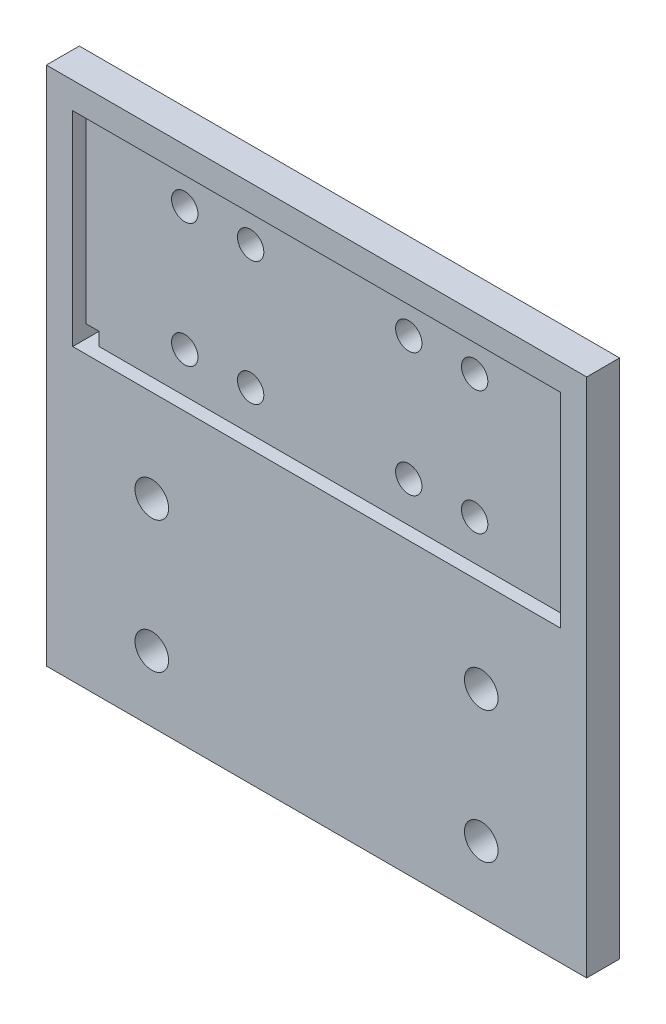
from build123d import *

# Parameters (mm, degrees)
SKETCH1_R           = 2.55
BOSS_EXTRUDE1_DEPTH = 5
SKETCH3_R           = 2.55
SKETCH3_W           = 74
SKETCH3_H           = 31
CUT_EXTRUDE1_DEPTH  = 2
SKETCH4_R           = 2
SKETCH4_W           = 2
SKETCH4_H           = 2
CUT_EXTRUDE2_DEPTH  = 5


with BuildPart() as part:
    # Sketch1 → Boss-Extrude1 (new body)
    with BuildSketch(Plane.XY):
        Polygon((-41, -19.5), (-41, -59.5), (41, -59.5), (41, -19.5), (41, 19.5), (-41, 19.5), align=None)
        with Locations((-25, -29.5)):
            Circle(SKETCH1_R, mode=Mode.SUBTRACT)
        with Locations((-25, -49.5)):
            Circle(SKETCH1_R, mode=Mode.SUBTRACT)
        with Locations((25, -49.5)):
            Circle(SKETCH1_R, mode=Mode.SUBTRACT)
        with Locations((25, -29.5)):
            Circle(SKETCH1_R, mode=Mode.SUBTRACT)
    extrude(amount=BOSS_EXTRUDE1_DEPTH)

    # Sketch3 → Cut-Extrude1 (cut)
    with BuildSketch(Plane.XY.offset(5)):
        with Locations((25, -29.5)):
            Circle(SKETCH3_R)
        with Locations((25, -49.5)):
            Circle(SKETCH3_R)
        with Locations((-25, -49.5)):
            Circle(SKETCH3_R)
        with Locations((-25, -29.5)):
            Circle(SKETCH3_R)
        Rectangle(SKETCH3_W, SKETCH3_H)
    extrude(amount=-CUT_EXTRUDE1_DEPTH, mode=Mode.SUBTRACT)

    # Sketch4 → Cut-Extrude2 (cut)
    with BuildSketch(Plane.XY.offset(3)):
        with Locations((-22, 9.4)):
            Circle(SKETCH4_R)
        with Locations((-12, 9.4)):
            Circle(SKETCH4_R)
        with Locations((12, 9.4)):
            Circle(SKETCH4_R)
        with Locations((22, 9.4)):
            Circle(SKETCH4_R)
        with Locations((22, -9.4)):
            Circle(SKETCH4_R)
        with Locations((12, -9.4)):
            Circle(SKETCH4_R)
        with Locations((-12, -9.4)):
            Circle(SKETCH4_R)
        with Locations((-22, -9.4)):
            Circle(SKETCH4_R)
        with Locations((-36, -14.5)):
            Rectangle(SKETCH4_W, SKETCH4_H)
        with Locations((-36, 14.5)):
            Rectangle(SKETCH4_W, SKETCH4_H)
        with Locations((36, 14.5)):
            Rectangle(SKETCH4_W, SKETCH4_H)
        with Locations((36, -14.5)):
            Rectangle(SKETCH4_W, SKETCH4_H)
    extrude(amount=-CUT_EXTRUDE2_DEPTH, mode=Mode.SUBTRACT)


solid = part.part
